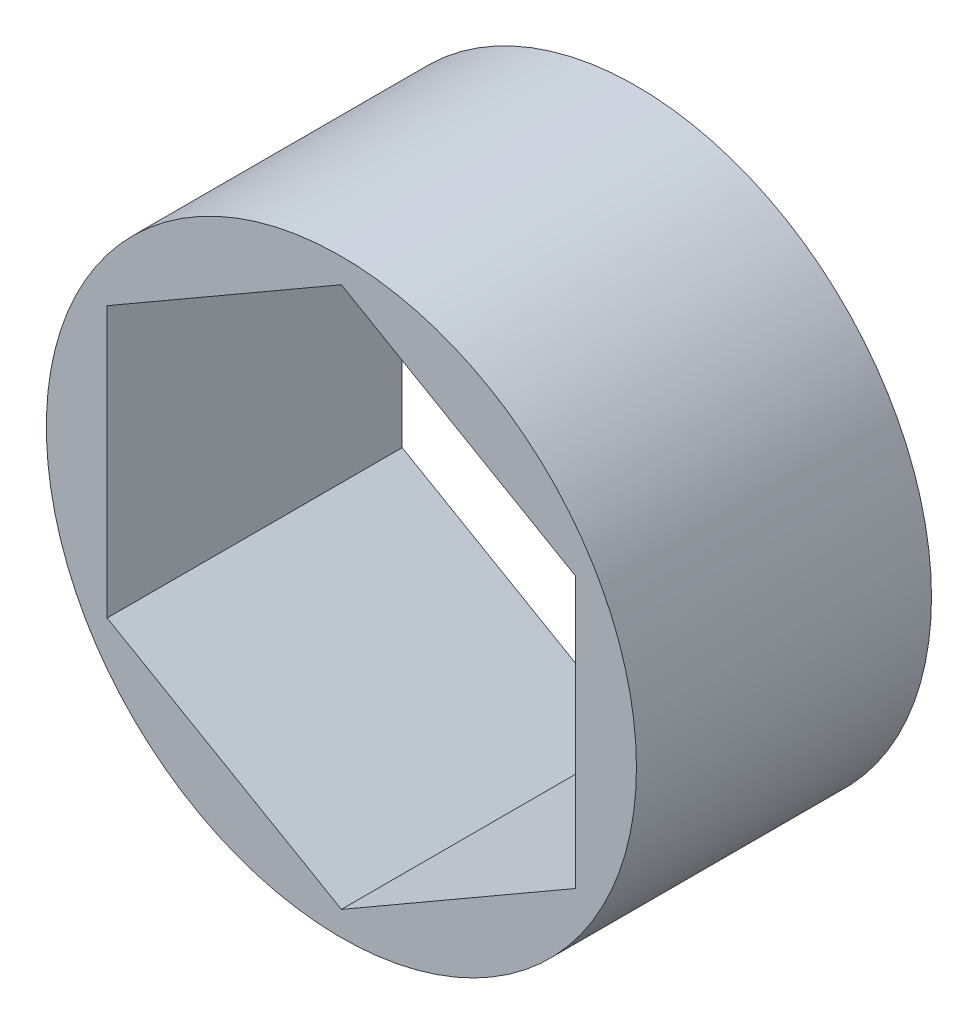
from build123d import *

# Parameters (mm, degrees)
SKETCH1_R               = 12
SKETCH1_R_2             = 6.4
BOSS_EXTRUDE1_DEPTH     = 6
CUT_EXTRUDE4_DEPTH      = 19
CUT_EXTRUDE4_DEPTH_BACK = 19


with BuildPart() as part:
    # Sketch1 → Boss-Extrude1 (new, symmetric)
    with BuildSketch(Plane.XY):
        Circle(SKETCH1_R)
        Circle(SKETCH1_R_2, mode=Mode.SUBTRACT)
    extrude(amount=BOSS_EXTRUDE1_DEPTH, both=True)

    # Sketch1_4 → Cut-Extrude4 (cut, two sides: drawn at the far end of the back side and taken through both)
    with BuildSketch(Plane.XY.offset(-CUT_EXTRUDE4_DEPTH_BACK)):
        Polygon((-9.526279442, -5.5), (0, -11), (9.526279442, -5.5), (9.526279442, 5.5), (0, 11), (-9.526279442, 5.5), align=None)
    extrude(amount=CUT_EXTRUDE4_DEPTH + CUT_EXTRUDE4_DEPTH_BACK, mode=Mode.SUBTRACT)


solid = part.part
